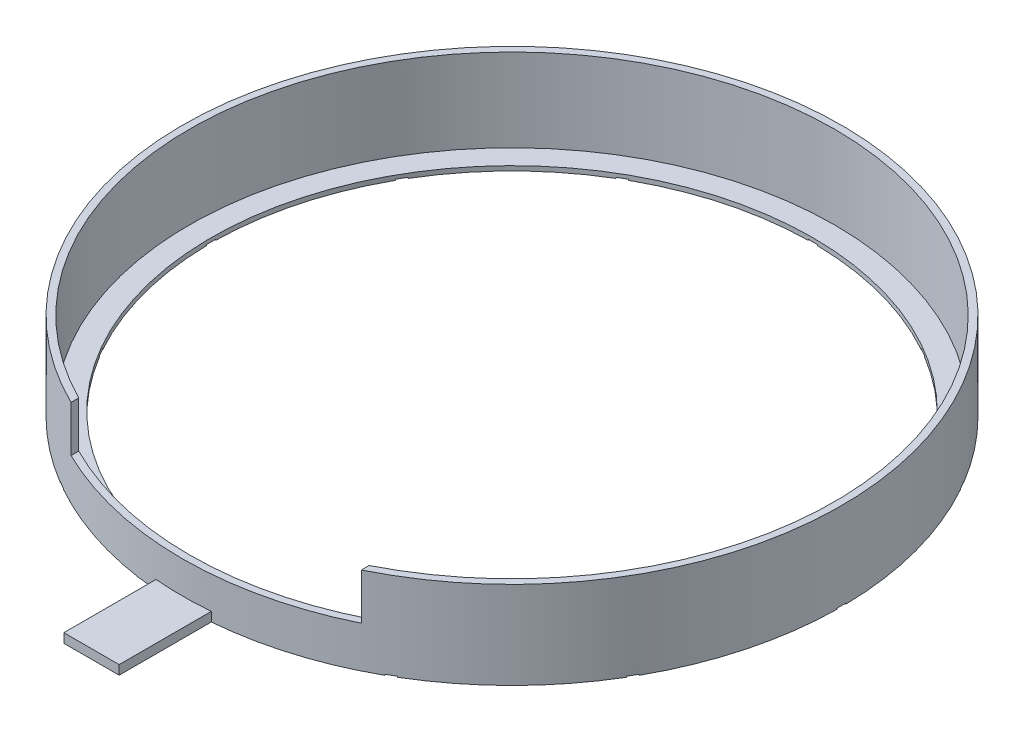
from build123d import *

# Parameters (mm, degrees)
SKETCH_1_R          = 71.5
SKETCH_1_R_2        = 70
EXTRUDE_1_DEPTH     = 19
SKETCH_2_R          = 71.5
SKETCH_2_R_2        = 65.25
EXTRUDE_2_DEPTH     = 1
CUT_EXTRUDE_1_DEPTH = 10
EXTRUDE_4_DEPTH     = 2
CUT_EXTRUDE_2_DEPTH = 0.2


with BuildPart() as part:
    # 草图1 → 凸台-拉伸1 (new body)
    with BuildSketch(Plane(origin=(0, 0, 0), x_dir=(1, 0, 0), z_dir=(0, 1, 0))):
        Circle(SKETCH_1_R)
        Circle(SKETCH_1_R_2, mode=Mode.SUBTRACT)
    extrude(amount=EXTRUDE_1_DEPTH)

    # 草图2 → 凸台-拉伸2 (add)
    with BuildSketch(Plane.XZ):
        Circle(SKETCH_2_R)
        Circle(SKETCH_2_R_2, mode=Mode.SUBTRACT)
    extrude(amount=-EXTRUDE_2_DEPTH)

    # 草图4 → 切除-拉伸1 (cut)
    with BuildSketch(Plane(origin=(0, 19, 0), x_dir=(1, 0, 0), z_dir=(0, 1, 0))):
        Polygon((-31.5, 0), (-31.5, -83.475080556), (0, -83.475080556), (31.5, -83.475080556), (31.5, 0), align=None)
    extrude(amount=-CUT_EXTRUDE_1_DEPTH, mode=Mode.SUBTRACT)

    # 草图5 → 凸台-拉伸4 (add)
    with BuildSketch(Plane.XZ):
        with BuildLine():
            Line((6, 71.247806984), (6, 91.247806984))
            Line((6, 91.247806984), (-6, 91.247806984))
            Line((-6, 91.247806984), (-6, 71.247806984))
            ThreePointArc((-6, 71.247806984), (0, 71.5), (6, 71.247806984))
        make_face()
    extrude(amount=-EXTRUDE_4_DEPTH)

    # 草图6 → 切除-拉伸2 (cut)
    with BuildSketch(Plane.XZ):
        with BuildLine():
            Line((-1, -65.242336715), (-1, -71.493006651))
            ThreePointArc((-1, -71.493006651), (0, -71.5), (1, -71.493006651))
            Line((1, -71.493006651), (1, -65.242336715))
            ThreePointArc((1, -65.242336715), (0, -65.25), (-1, -65.242336715))
        make_face()
        with BuildLine():
            Line((1, -65.242336715), (-1, -65.242336715))
            ThreePointArc((-1, -65.242336715), (0, -65.25), (1, -65.242336715))
        make_face()
        with BuildLine():
            Line((-33.487193761, -56.001520997), (-36.612528729, -61.414759953))
            ThreePointArc((-36.612528729, -61.414759953), (-35.75, -61.920816371), (-34.880477922, -62.414759953))
            Line((-34.880477922, -62.414759953), (-31.755142954, -57.001520997))
            ThreePointArc((-31.755142954, -57.001520997), (-32.625, -56.508157597), (-33.487193761, -56.001520997))
        make_face()
        with BuildLine():
            Line((-57.001520997, -31.755142954), (-62.414759953, -34.880477922))
            ThreePointArc((-62.414759953, -34.880477922), (-61.920816371, -35.75), (-61.414759953, -36.612528729))
            Line((-61.414759953, -36.612528729), (-56.001520997, -33.487193761))
            ThreePointArc((-56.001520997, -33.487193761), (-56.508157597, -32.625), (-57.001520997, -31.755142954))
        make_face()
        with BuildLine():
            Line((-65.242336715, 1), (-71.493006651, 1))
            ThreePointArc((-71.493006651, 1), (-71.5, 0), (-71.493006651, -1))
            Line((-71.493006651, -1), (-65.242336715, -1))
            ThreePointArc((-65.242336715, -1), (-65.25, 0), (-65.242336715, 1))
        make_face()
        with BuildLine():
            Line((-56.001520997, 33.487193761), (-61.414759953, 36.612528729))
            ThreePointArc((-61.414759953, 36.612528729), (-61.920816371, 35.75), (-62.414759953, 34.880477922))
            Line((-62.414759953, 34.880477922), (-57.001520997, 31.755142954))
            ThreePointArc((-57.001520997, 31.755142954), (-56.508157597, 32.625), (-56.001520997, 33.487193761))
        make_face()
        with BuildLine():
            Line((-31.755142954, 57.001520997), (-34.880477922, 62.414759953))
            ThreePointArc((-34.880477922, 62.414759953), (-35.75, 61.920816371), (-36.612528729, 61.414759953))
            Line((-36.612528729, 61.414759953), (-33.487193761, 56.001520997))
            ThreePointArc((-33.487193761, 56.001520997), (-32.625, 56.508157597), (-31.755142954, 57.001520997))
        make_face()
        with BuildLine():
            Line((1, 65.242336715), (1, 71.493006651))
            ThreePointArc((1, 71.493006651), (0, 71.5), (-1, 71.493006651))
            Line((-1, 71.493006651), (-1, 65.242336715))
            ThreePointArc((-1, 65.242336715), (0, 65.25), (1, 65.242336715))
        make_face()
        with BuildLine():
            Line((33.487193761, 56.001520997), (36.612528729, 61.414759953))
            ThreePointArc((36.612528729, 61.414759953), (35.75, 61.920816371), (34.880477922, 62.414759953))
            Line((34.880477922, 62.414759953), (31.755142954, 57.001520997))
            ThreePointArc((31.755142954, 57.001520997), (32.625, 56.508157597), (33.487193761, 56.001520997))
        make_face()
        with BuildLine():
            Line((57.001520997, 31.755142954), (62.414759953, 34.880477922))
            ThreePointArc((62.414759953, 34.880477922), (61.920816371, 35.75), (61.414759953, 36.612528729))
            Line((61.414759953, 36.612528729), (56.001520997, 33.487193761))
            ThreePointArc((56.001520997, 33.487193761), (56.508157597, 32.625), (57.001520997, 31.755142954))
        make_face()
        with BuildLine():
            Line((65.242336715, -1), (71.493006651, -1))
            ThreePointArc((71.493006651, -1), (71.5, 0), (71.493006651, 1))
            Line((71.493006651, 1), (65.242336715, 1))
            ThreePointArc((65.242336715, 1), (65.25, 0), (65.242336715, -1))
        make_face()
        with BuildLine():
            Line((56.001520997, -33.487193761), (61.414759953, -36.612528729))
            ThreePointArc((61.414759953, -36.612528729), (61.920816371, -35.75), (62.414759953, -34.880477922))
            Line((62.414759953, -34.880477922), (57.001520997, -31.755142954))
            ThreePointArc((57.001520997, -31.755142954), (56.508157597, -32.625), (56.001520997, -33.487193761))
        make_face()
        with BuildLine():
            Line((31.755142954, -57.001520997), (34.880477922, -62.414759953))
            ThreePointArc((34.880477922, -62.414759953), (35.75, -61.920816371), (36.612528729, -61.414759953))
            Line((36.612528729, -61.414759953), (33.487193761, -56.001520997))
            ThreePointArc((33.487193761, -56.001520997), (32.625, -56.508157597), (31.755142954, -57.001520997))
        make_face()
    extrude(amount=-CUT_EXTRUDE_2_DEPTH, mode=Mode.SUBTRACT)


solid = part.part
